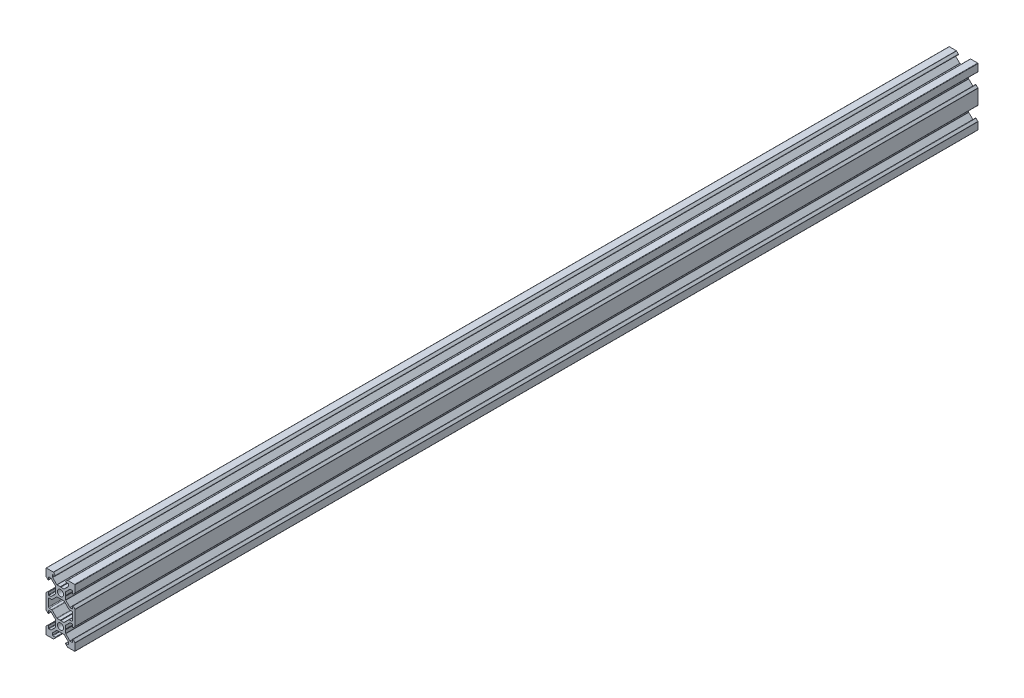
from build123d import *

# Parameters (mm, degrees)
SKETCH1_R           = 2.1
BOSS_EXTRUDE1_DEPTH = 622.69
FILLET1_R           = 0.25
FILLET2_R           = 0.5
CUT_EXTRUDE1_DEPTH  = 623.69


with BuildPart() as part:
    # Sketch1 → Boss-Extrude1 (new body)
    with BuildSketch(Plane.XY):
        Polygon((3.560660172, -2.5), (3.560660172, 2.5), (6.560660172, 5.5), (8.252142372, 5.5), (8.252142372, 3.1), (10, 4.847857628), (10, 10), (4.847857628, 10), (3.1, 8.252142372), (5.5, 8.252142372), (5.5, 6.560660172), (2.5, 3.560660172), (-2.5, 3.560660172), (-5.5, 6.560660172), (-5.5, 8.252142372), (-3.1, 8.252142372), (-4.847857628, 10), (-10, 10), (-10, 4.847857628), (-8.252142372, 3.1), (-8.252142372, 5.5), (-6.560660172, 5.5), (-3.560660172, 2.5), (-3.560660172, -2.5), (-6.560660172, -5.5), (-8.252142372, -5.5), (-8.252142372, -3.1), (-10, -4.847857628), (-10, -7), (-10, -13), (-10, -15.152142372), (-8.252142372, -16.9), (-8.252142372, -14.5), (-6.560660172, -14.5), (-3.560660172, -17.5), (-3.560660172, -22.5), (-6.560660172, -25.5), (-8.252142372, -25.5), (-8.252142372, -23.1), (-10, -24.847857628), (-10, -30), (-4.847857628, -30), (-3.1, -28.252142372), (-5.5, -28.252142372), (-5.5, -26.560660172), (-2.5, -23.560660172), (2.5, -23.560660172), (5.5, -26.560660172), (5.5, -28.252142372), (3.1, -28.252142372), (4.847857628, -30), (10, -30), (10, -24.847857628), (8.252142372, -23.1), (8.252142372, -25.5), (6.560660172, -25.5), (3.560660172, -22.5), (3.560660172, -17.5), (6.560660172, -14.5), (8.252142372, -14.5), (8.252142372, -16.9), (10, -15.152142372), (10, -13), (10, -7), (10, -4.847857628), (8.252142372, -3.1), (8.252142372, -5.5), (6.560660172, -5.5), align=None)
        Circle(SKETCH1_R, mode=Mode.SUBTRACT)
        with Locations((0, -20)):
            Circle(SKETCH1_R, mode=Mode.SUBTRACT)
        Polygon((2.5, -3.560660172), (-2.5, -3.560660172), (-5.5, -6.560660172), (-5.939339828, -7), (-8.252142372, -7), (-8.252142372, -13), (-5.939339828, -13), (-5.5, -13.439339828), (-2.5, -16.439339828), (2.5, -16.439339828), (5.5, -13.439339828), (5.939339828, -13), (8.252142372, -13), (8.252142372, -7), (5.939339828, -7), (5.5, -6.560660172), align=None, mode=Mode.SUBTRACT)
    extrude(amount=BOSS_EXTRUDE1_DEPTH)

    # Fillet1
    fillet1_edges = [part.edges().sort_by_distance(p)[0] for p in [
        (5.5, 6.560660172, 311.345),
        (5.5, 8.252142372, 311.345),
        (3.1, 8.252142372, 311.345),
        (4.847857628, 10, 311.345),
        (10, 10, 311.345),
        (10, 4.847857628, 311.345),
        (8.252142372, 3.1, 311.345),
        (8.252142372, 5.5, 311.345),
        (6.560660172, 5.5, 311.345),
        (3.560660172, 2.5, 311.345),
        (3.560660172, -2.5, 311.345),
        (6.560660172, -5.5, 311.345),
        (8.252142372, -5.5, 311.345),
        (8.252142372, -3.1, 311.345),
        (10, -4.847857628, 311.345),
        (10, -15.152142372, 311.345),
        (8.252142372, -16.9, 311.345),
        (8.252142372, -14.5, 311.345),
        (6.560660172, -14.5, 311.345),
        (3.560660172, -17.5, 311.345),
        (3.560660172, -22.5, 311.345),
        (6.560660172, -25.5, 311.345),
        (8.252142372, -25.5, 311.345),
        (8.252142372, -23.1, 311.345),
        (10, -24.847857628, 311.345),
        (10, -30, 311.345),
        (4.847857628, -30, 311.345),
        (3.1, -28.252142372, 311.345),
        (5.5, -28.252142372, 311.345),
        (5.5, -26.560660172, 311.345),
        (2.5, -23.560660172, 311.345),
        (-2.5, -23.560660172, 311.345),
        (-5.5, -26.560660172, 311.345),
        (-5.5, -28.252142372, 311.345),
        (-3.1, -28.252142372, 311.345),
        (-4.847857628, -30, 311.345),
        (-10, -30, 311.345),
        (-10, -24.847857628, 311.345),
        (-8.252142372, -23.1, 311.345),
        (-8.252142372, -25.5, 311.345),
        (-6.560660172, -25.5, 311.345),
        (-3.560660172, -22.5, 311.345),
        (-3.560660172, -17.5, 311.345),
        (-6.560660172, -14.5, 311.345),
        (-8.252142372, -14.5, 311.345),
        (-8.252142372, -16.9, 311.345),
        (-10, -15.152142372, 311.345),
        (-10, -4.847857628, 311.345),
        (-8.252142372, -3.1, 311.345),
        (-8.252142372, -5.5, 311.345),
        (-6.560660172, -5.5, 311.345),
        (-3.560660172, -2.5, 311.345),
        (-3.560660172, 2.5, 311.345),
        (-6.560660172, 5.5, 311.345),
        (-8.252142372, 5.5, 311.345),
        (-8.252142372, 3.1, 311.345),
        (-10, 4.847857628, 311.345),
        (-10, 10, 311.345),
        (-4.847857628, 10, 311.345),
        (-3.1, 8.252142372, 311.345),
        (-5.5, 8.252142372, 311.345),
        (-5.5, 6.560660172, 311.345),
        (-2.5, 3.560660172, 311.345),
        (2.5, 3.560660172, 311.345),
    ]]
    fillet(fillet1_edges, radius=FILLET1_R)

    # Fillet2
    fillet2_edges = [part.edges().sort_by_distance(p)[0] for p in [
        (-2.5, -3.560660172, 311.345),
        (-5.939339828, -7, 311.345),
        (-8.252142372, -7, 311.345),
        (-8.252142372, -13, 311.345),
        (-5.939339828, -13, 311.345),
        (-2.5, -16.439339828, 311.345),
        (2.5, -16.439339828, 311.345),
        (5.939339828, -13, 311.345),
        (8.252142372, -13, 311.345),
        (8.252142372, -7, 311.345),
        (5.939339828, -7, 311.345),
        (2.5, -3.560660172, 311.345),
    ]]
    fillet(fillet2_edges, radius=FILLET2_R)

    # Sketch2 → Cut-Extrude1 (cut, through all)
    with BuildSketch(Plane.XY.offset(622.69)):
        Polygon((0, 3.398953432), (-0.242280927, 3.560660172), (0.242280927, 3.560660172), align=None)
        Polygon((0, -3.398953432), (0.242280927, -3.560660172), (-0.242280927, -3.560660172), align=None)
        Polygon((3.560660172, 0.242280927), (3.560660172, -0.242280927), (3.398953432, 0), align=None)
        Polygon((-3.560660172, 0.242280927), (-3.560660172, -0.242280927), (-3.398953432, 0), align=None)
        Polygon((-3.398953432, -20), (-3.560660172, -20.242280927), (-3.560660172, -19.757719073), align=None)
        Polygon((3.398953432, -20), (3.560660172, -19.757719073), (3.560660172, -20.242280927), align=None)
        Polygon((-0.242280927, -16.439339828), (0.242280927, -16.439339828), (0, -16.601046568), align=None)
        Polygon((-0.242280927, -23.560660172), (0.242280927, -23.560660172), (0, -23.398953432), align=None)
    extrude(amount=-CUT_EXTRUDE1_DEPTH, mode=Mode.SUBTRACT)


solid = part.part
